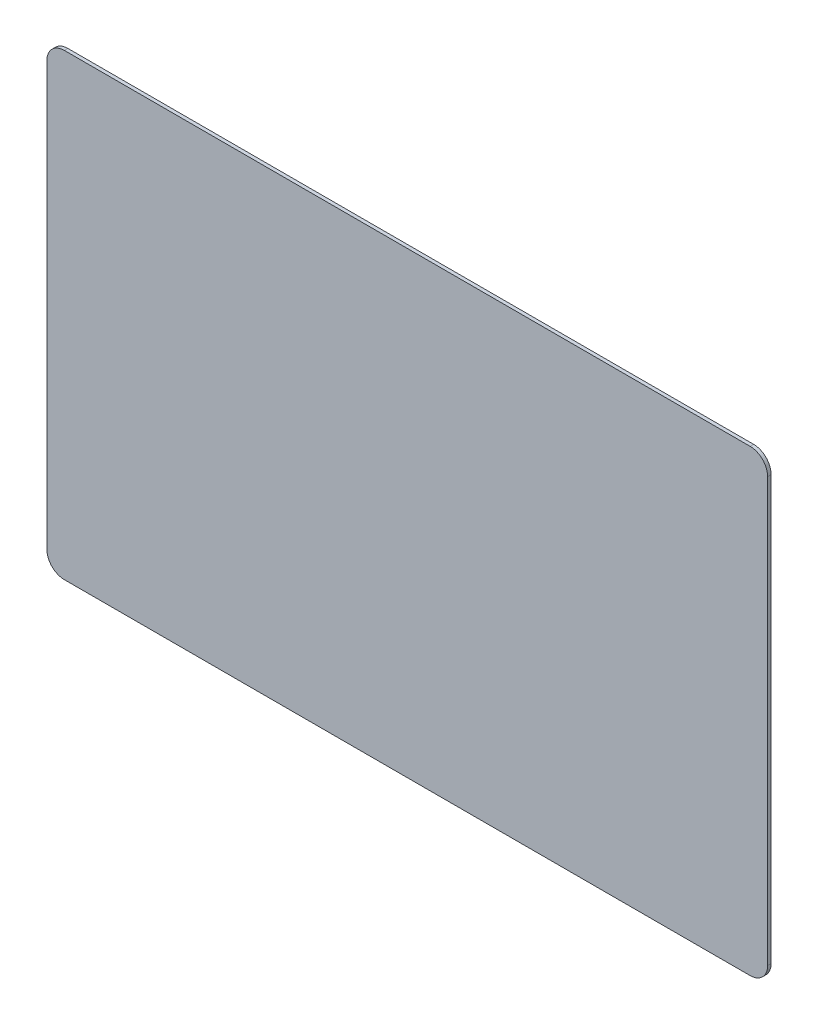
from build123d import *

# Parameters (mm, degrees)
Y_KSEKLIK_EKSTR_ZYON1_DEPTH = 2


with BuildPart() as part:
    # Çizim1 → Yükseklik-Ekstrüzyon1 (new body)
    with BuildSketch(Plane.XY):
        with BuildLine():
            Line((-124.502923218, 127.458505468), (267.497076782, 127.458505468))
            ThreePointArc((267.497076782, 127.458505468), (274.568144594, 124.52957328), (277.497076782, 117.458505468))
            Line((277.497076782, 117.458505468), (277.497076782, -124.541494532))
            ThreePointArc((277.497076782, -124.541494532), (274.568144594, -131.612562344), (267.497076782, -134.541494532))
            Line((267.497076782, -134.541494532), (-124.502923218, -134.541494532))
            ThreePointArc((-124.502923218, -134.541494532), (-131.57399103, -131.612562344), (-134.502923218, -124.541494532))
            Line((-134.502923218, -124.541494532), (-134.502923218, 117.458505468))
            ThreePointArc((-134.502923218, 117.458505468), (-131.57399103, 124.52957328), (-124.502923218, 127.458505468))
        make_face()
    extrude(amount=Y_KSEKLIK_EKSTR_ZYON1_DEPTH)


solid = part.part
